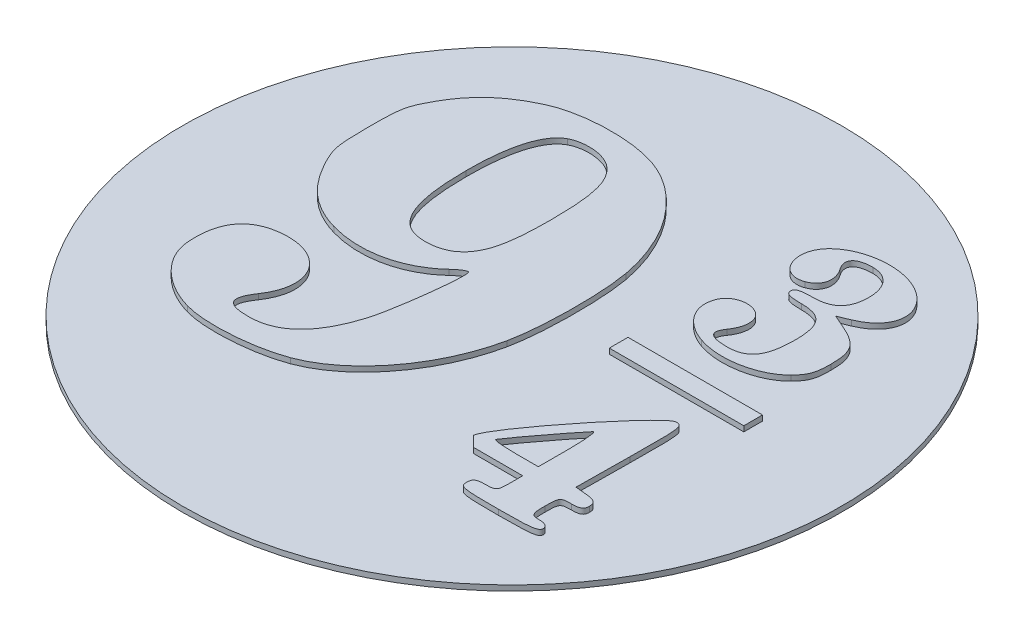
from build123d import *

# Parameters (mm, degrees)
SKETCH_1_R          = 24.7
EXTRUDE_3_DEPTH     = 0.4
EXTRUDE_9_4_3_DEPTH = 0.4


with BuildPart() as part:
    # 草图1 → 凸台-拉伸3 (new body)
    with BuildSketch(Plane(origin=(0, 0, 0), x_dir=(1, 0, 0), z_dir=(0, 1, 0))):
        Circle(SKETCH_1_R)
    extrude(amount=EXTRUDE_3_DEPTH)

    # 草图10 → 凸台-拉伸-9-4-3 (add)
    with BuildSketch(Plane(origin=(0, 0.4, 0), x_dir=(1, 0, 0), z_dir=(0, 1, 0))):
        with BuildLine():
            Line((11.175084771, -11.353611454), (11.175084771, -10.373611454))
            Line((11.175084771, -10.373611454), (7.481550162, -10.373611454))
            Line((7.481550162, -10.373611454), (6.707631571, -9.603611454))
            add(Edge.make_bspline(
                [(6.707631571, -9.603611454), (6.724683571, -8.557262654), (12.625453971, -1.133611454), (13.440108371, -1.133611454)],
                knots=[0, 0, 0, 0, 1, 1, 1, 1], degree=3))
            add(Edge.make_bspline(
                [(13.440108371, -1.133611454), (13.977638371, -1.133611454), (13.999525971, -1.302515854), (13.957184371, -5.123611454)],
                knots=[0, 0, 0, 0, 1, 1, 1, 1], degree=3))
            Line((13.957184371, -5.123611454), (13.912969571, -9.113611454))
            Line((13.912969571, -9.113611454), (14.784027171, -9.201352254))
            add(Edge.make_bspline(
                [(14.784027171, -9.201352254), (15.428715971, -9.266289854), (15.655084771, -9.430014254), (15.655084771, -9.831352254)],
                knots=[0, 0, 0, 0, 1, 1, 1, 1], degree=3))
            add(Edge.make_bspline(
                [(15.655084771, -9.831352254), (15.655084771, -10.247197054), (15.459258371, -10.373611454), (14.815084771, -10.373611454)],
                knots=[0, 0, 0, 0, 1, 1, 1, 1], degree=3))
            add(Edge.make_bspline(
                [(14.815084771, -10.373611454), (14.021752371, -10.373611454), (13.975084771, -10.435833054), (13.975084771, -11.493611454)],
                knots=[0, 0, 0, 0, 1, 1, 1, 1], degree=3))
            add(Edge.make_bspline(
                [(13.975084771, -11.493611454), (13.975084771, -12.501611454), (14.045084771, -12.613611454), (14.675084771, -12.613611454)],
                knots=[0, 0, 0, 0, 1, 1, 1, 1], degree=3))
            add(Edge.make_bspline(
                [(14.675084771, -12.613611454), (15.110641571, -12.613611454), (15.375084771, -12.772279054), (15.375084771, -13.033611454)],
                knots=[0, 0, 0, 0, 1, 1, 1, 1], degree=3))
            add(Edge.make_bspline(
                [(15.375084771, -13.033611454), (15.375084771, -13.380279454), (14.861752371, -13.453611454), (12.435084771, -13.453611454)],
                knots=[0, 0, 0, 0, 1, 1, 1, 1], degree=3))
            add(Edge.make_bspline(
                [(12.435084771, -13.453611454), (9.681752371, -13.453611454), (9.495084771, -13.418057054), (9.495084771, -12.893611454)],
                knots=[0, 0, 0, 0, 1, 1, 1, 1], degree=3))
            add(Edge.make_bspline(
                [(9.495084771, -12.893611454), (9.495084771, -12.458054654), (9.681752371, -12.333611454), (10.335084771, -12.333611454)],
                knots=[0, 0, 0, 0, 1, 1, 1, 1], degree=3))
            add(Edge.make_bspline(
                [(10.335084771, -12.333611454), (11.108416771, -12.333611454), (11.175084771, -12.255833054), (11.175084771, -11.353611454)],
                knots=[0, 0, 0, 0, 1, 1, 1, 1], degree=3))
        make_face()
        with BuildLine():
            Line((9.495084771, -9.200945625), (11.175084771, -9.200945625))
            Line((11.175084771, -9.200945625), (11.175084771, -6.904945625))
            add(Edge.make_bspline(
                [(11.175084771, -6.904945625), (11.175084771, -5.642145625), (11.071686371, -4.728645625), (10.945311171, -4.874945625)],
                knots=[0, 0, 0, 0, 1, 1, 1, 1], degree=3))
            add(Edge.make_bspline(
                [(10.945311171, -4.874945625), (10.120386371, -5.829933225), (7.815084771, -8.890459225), (7.815084771, -9.030646825)],
                knots=[0, 0, 0, 0, 1, 1, 1, 1], degree=3))
            add(Edge.make_bspline(
                [(7.815084771, -9.030646825), (7.815084771, -9.124312425), (8.571084771, -9.200945625), (9.495084771, -9.200945625)],
                knots=[0, 0, 0, 0, 1, 1, 1, 1], degree=3))
        make_face(mode=Mode.SUBTRACT)
        Polygon((6.135084771, 1.859054375), (6.135084771, 2.559054375), (11.175084771, 2.559054375), (16.215084771, 2.559054375), (16.215084771, 1.859054375), (16.215084771, 1.159054375), (11.175084771, 1.159054375), (6.135084771, 1.159054375), align=None)
        with BuildLine():
            Line((13.382193171, 12.065430695), (12.549789571, 11.720637015))
            Line((12.549789571, 11.720637015), (13.612437171, 11.244219535))
            add(Edge.make_bspline(
                [(13.612437171, 11.244219535), (15.107141571, 10.574098615), (15.482778371, 10.006284935), (15.482778371, 8.417008575)],
                knots=[0, 0, 0, 0, 1, 1, 1, 1], degree=3))
            add(Edge.make_bspline(
                [(15.482778371, 8.417008575), (15.482778371, 7.293957695), (15.339729171, 6.892793855), (14.701861171, 6.227002855)],
                knots=[0, 0, 0, 0, 1, 1, 1, 1], degree=3))
            add(Edge.make_bspline(
                [(14.701861171, 6.227002855), (13.503909171, 4.976609935), (10.946918371, 4.481593455), (9.075084771, 5.137696175)],
                knots=[0, 0, 0, 0, 1, 1, 1, 1], degree=3))
            add(Edge.make_bspline(
                [(9.075084771, 5.137696175), (7.376445171, 5.733092375), (6.499487971, 7.048142055), (6.972111171, 8.291234255)],
                knots=[0, 0, 0, 0, 1, 1, 1, 1], degree=3))
            add(Edge.make_bspline(
                [(6.972111171, 8.291234255), (7.281737971, 9.105612295), (8.360009571, 9.456676575), (9.189005571, 9.013011535)],
                knots=[0, 0, 0, 0, 1, 1, 1, 1], degree=3))
            add(Edge.make_bspline(
                [(9.189005571, 9.013011535), (9.892331971, 8.636602775), (9.947253971, 7.689465535), (9.317864371, 6.790884215)],
                knots=[0, 0, 0, 0, 1, 1, 1, 1], degree=3))
            add(Edge.make_bspline(
                [(9.317864371, 6.790884215), (8.768579971, 6.006672815), (9.132011571, 5.647629655), (10.475084771, 5.647629655)],
                knots=[0, 0, 0, 0, 1, 1, 1, 1], degree=3))
            add(Edge.make_bspline(
                [(10.475084771, 5.647629655), (11.963228771, 5.647629655), (12.575084771, 6.519003935), (12.575084771, 8.638344935)],
                knots=[0, 0, 0, 0, 1, 1, 1, 1], degree=3))
            add(Edge.make_bspline(
                [(12.575084771, 8.638344935), (12.575084771, 10.562571295), (12.024713971, 11.239054375), (10.459208771, 11.239054375)],
                knots=[0, 0, 0, 0, 1, 1, 1, 1], degree=3))
            add(Edge.make_bspline(
                [(10.459208771, 11.239054375), (9.539988371, 11.239054375), (9.215084771, 11.348737375), (9.215084771, 11.659054375)],
                knots=[0, 0, 0, 0, 1, 1, 1, 1], degree=3))
            add(Edge.make_bspline(
                [(9.215084771, 11.659054375), (9.215084771, 11.969371375), (9.539988371, 12.079054375), (10.459208771, 12.079054375)],
                knots=[0, 0, 0, 0, 1, 1, 1, 1], degree=3))
            add(Edge.make_bspline(
                [(10.459208771, 12.079054375), (11.895902771, 12.079054375), (12.575084771, 12.753139255), (12.575084771, 14.179054375)],
                knots=[0, 0, 0, 0, 1, 1, 1, 1], degree=3))
            add(Edge.make_bspline(
                [(12.575084771, 14.179054375), (12.575084771, 15.466329175), (11.877845571, 16.279054375), (10.773491971, 16.279054375)],
                knots=[0, 0, 0, 0, 1, 1, 1, 1], degree=3))
            add(Edge.make_bspline(
                [(10.773491971, 16.279054375), (9.535015571, 16.279054375), (9.091907171, 15.739519015), (9.661964771, 14.925646095)],
                knots=[0, 0, 0, 0, 1, 1, 1, 1], degree=3))
            add(Edge.make_bspline(
                [(9.661964771, 14.925646095), (10.280700371, 14.042276615), (10.059998771, 13.121075775), (9.153563171, 12.803619335)],
                knots=[0, 0, 0, 0, 1, 1, 1, 1], degree=3))
            add(Edge.make_bspline(
                [(9.153563171, 12.803619335), (7.498424371, 12.223945975), (6.575519171, 14.504944135), (7.920865971, 15.850289815)],
                knots=[0, 0, 0, 0, 1, 1, 1, 1], degree=3))
            add(Edge.make_bspline(
                [(7.920865971, 15.850289815), (9.451998371, 17.381423335), (12.701053971, 17.469146215), (14.319518371, 16.023050375)],
                knots=[0, 0, 0, 0, 1, 1, 1, 1], degree=3))
            add(Edge.make_bspline(
                [(14.319518371, 16.023050375), (15.802963971, 14.697590575), (15.375067971, 12.890906255), (13.382193171, 12.065430695)],
                knots=[0, 0, 0, 0, 1, 1, 1, 1], degree=3))
        make_face()
        with BuildLine():
            add(Edge.make_bspline(
                [(-12.395160109, -11.908850825), (-14.684682589, -11.260034825), (-16.395066509, -9.567661625), (-16.546787869, -7.800945625)],
                knots=[0, 0, 0, 0, 1, 1, 1, 1], degree=3))
            add(Edge.make_bspline(
                [(-16.546787869, -7.800945625), (-16.759731509, -5.321327225), (-15.790793749, -3.916516825), (-13.705470789, -3.681470825)],
                knots=[0, 0, 0, 0, 1, 1, 1, 1], degree=3))
            add(Edge.make_bspline(
                [(-13.705470789, -3.681470825), (-10.507238269, -3.320983425), (-8.805372509, -5.890558825), (-10.545899549, -8.451973625)],
                knots=[0, 0, 0, 0, 1, 1, 1, 1], degree=3))
            add(Edge.make_bspline(
                [(-10.545899549, -8.451973625), (-11.448565229, -9.780366425), (-11.128414349, -10.321427225), (-9.440630629, -10.319898425)],
                knots=[0, 0, 0, 0, 1, 1, 1, 1], degree=3))
            add(Edge.make_bspline(
                [(-9.440630629, -10.319898425), (-7.294269909, -10.317938425), (-5.800735069, -8.889277625), (-4.904704829, -5.980945625)],
                knots=[0, 0, 0, 0, 1, 1, 1, 1], degree=3))
            add(Edge.make_bspline(
                [(-4.904704829, -5.980945625), (-4.435035069, -4.456494025), (-3.821602669, 0.569075055), (-4.074344109, 0.821816495)],
                knots=[0, 0, 0, 0, 1, 1, 1, 1], degree=3))
            add(Edge.make_bspline(
                [(-4.074344109, 0.821816495), (-4.160371029, 0.907843415), (-4.575942269, 0.655299095), (-4.997835909, 0.260606895)],
                knots=[0, 0, 0, 0, 1, 1, 1, 1], degree=3))
            add(Edge.make_bspline(
                [(-4.997835909, 0.260606895), (-6.805234229, -1.430259905), (-9.523380989, -2.014550465), (-12.089151749, -1.263736345)],
                knots=[0, 0, 0, 0, 1, 1, 1, 1], degree=3))
            add(Edge.make_bspline(
                [(-12.089151749, -1.263736345), (-14.012791509, -0.700827145), (-15.361830109, 0.417667575), (-16.410962669, 2.319499535)],
                knots=[0, 0, 0, 0, 1, 1, 1, 1], degree=3))
            add(Edge.make_bspline(
                [(-16.410962669, 2.319499535), (-17.162930949, 3.682642015), (-17.238488109, 4.061030655), (-17.241548509, 6.479054375)],
                knots=[0, 0, 0, 0, 1, 1, 1, 1], degree=3))
            add(Edge.make_bspline(
                [(-17.241548509, 6.479054375), (-17.244617309, 8.903545255), (-17.171872749, 9.270911135), (-16.419922389, 10.628332935)],
                knots=[0, 0, 0, 0, 1, 1, 1, 1], degree=3))
            add(Edge.make_bspline(
                [(-16.419922389, 10.628332935), (-15.409978909, 12.451484895), (-14.119197949, 13.618452095), (-12.077691909, 14.554050255)],
                knots=[0, 0, 0, 0, 1, 1, 1, 1], degree=3))
            add(Edge.make_bspline(
                [(-12.077691909, 14.554050255), (-10.085727949, 15.466943775), (-6.552902989, 15.573853655), (-4.303248309, 14.789319415)],
                knots=[0, 0, 0, 0, 1, 1, 1, 1], degree=3))
            add(Edge.make_bspline(
                [(-4.303248309, 14.789319415), (-1.260796309, 13.728308975), (1.207945771, 10.490202215), (1.911623291, 6.637629855)],
                knots=[0, 0, 0, 0, 1, 1, 1, 1], degree=3))
            add(Edge.make_bspline(
                [(1.911623291, 6.637629855), (2.329347171, 4.350628215), (2.283790331, -0.011021945), (1.819295251, -2.201890065)],
                knots=[0, 0, 0, 0, 1, 1, 1, 1], degree=3))
            add(Edge.make_bspline(
                [(1.819295251, -2.201890065), (0.918676651, -6.449808425), (-1.926067349, -10.192529225), (-5.177652469, -11.407508025)],
                knots=[0, 0, 0, 0, 1, 1, 1, 1], degree=3))
            add(Edge.make_bspline(
                [(-5.177652469, -11.407508025), (-7.247404909, -12.180887625), (-10.610797949, -12.414514025), (-12.395160109, -11.908850825)],
                knots=[0, 0, 0, 0, 1, 1, 1, 1], degree=3))
        make_face()
        with BuildLine():
            add(Edge.make_bspline(
                [(-5.822945229, 1.723432735), (-4.749775789, 2.567587935), (-4.374074869, 4.018566975), (-4.374074869, 7.319054375)],
                knots=[0, 0, 0, 0, 1, 1, 1, 1], degree=3))
            add(Edge.make_bspline(
                [(-4.374074869, 7.319054375), (-4.374074869, 10.619541775), (-4.749775789, 12.070520815), (-5.822945229, 12.914676015)],
                knots=[0, 0, 0, 0, 1, 1, 1, 1], degree=3))
            add(Edge.make_bspline(
                [(-5.822945229, 12.914676015), (-6.608814789, 13.532840975), (-8.130337029, 13.656410575), (-9.029660069, 13.175107655)],
                knots=[0, 0, 0, 0, 1, 1, 1, 1], degree=3))
            add(Edge.make_bspline(
                [(-9.029660069, 13.175107655), (-10.162153949, 12.569015175), (-10.760741589, 10.533092335), (-10.751415349, 7.319054375)],
                knots=[0, 0, 0, 0, 1, 1, 1, 1], degree=3))
            add(Edge.make_bspline(
                [(-10.751415349, 7.319054375), (-10.742113749, 4.113760535), (-10.250830229, 2.329130975), (-9.169199469, 1.571527415)],
                knots=[0, 0, 0, 0, 1, 1, 1, 1], degree=3))
            add(Edge.make_bspline(
                [(-9.169199469, 1.571527415), (-8.324245709, 0.979698695), (-6.673163829, 1.054650775), (-5.822945229, 1.723432735)],
                knots=[0, 0, 0, 0, 1, 1, 1, 1], degree=3))
        make_face(mode=Mode.SUBTRACT)
    extrude(amount=EXTRUDE_9_4_3_DEPTH)


solid = part.part
